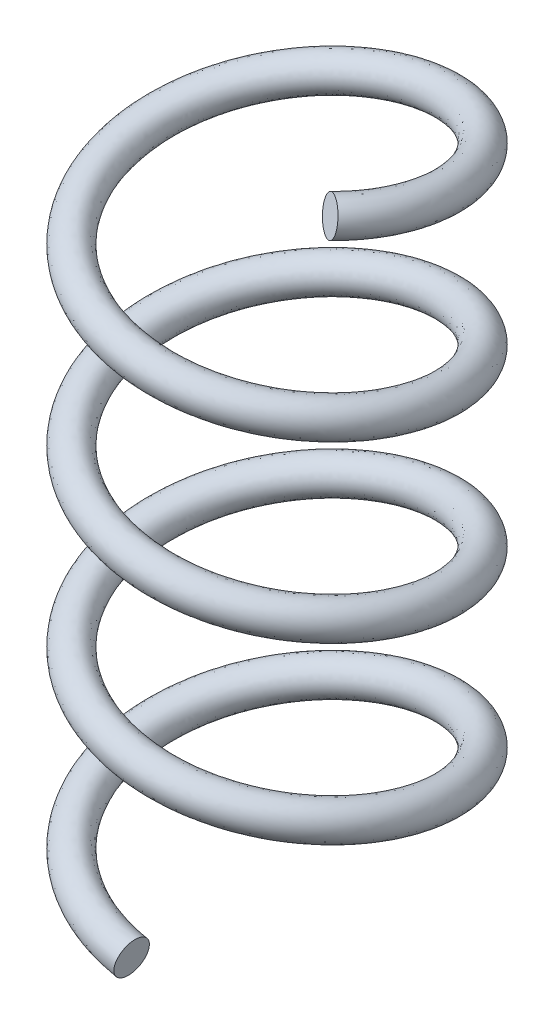
from build123d import *

# Parameters (mm, degrees)
BALAYAGE1_PITCH     = 6
BALAYAGE1_HEIGHT    = 23
BALAYAGE1_RADIUS    = 5
BALAYAGE1_PROFILE_R = 0.6


with BuildPart() as part:
    # Balayage1: sweep along a helix
    with BuildLine() as balayage1_path:
        Helix(BALAYAGE1_PITCH, BALAYAGE1_HEIGHT, BALAYAGE1_RADIUS, center=(0, 0, 0), direction=(0, 1, 0), lefthand=True)
    # Balayage1 profile (on start of the path) → Balayage1 (sweep)
    with BuildSketch(Plane(origin=(0, 0, 5), x_dir=(-0.187595247, -0.982246417, 0), z_dir=(-0.982246417, 0.187595247, 0))):
        Circle(BALAYAGE1_PROFILE_R)
    sweep(path=balayage1_path.line, is_frenet=True)


solid = part.part
